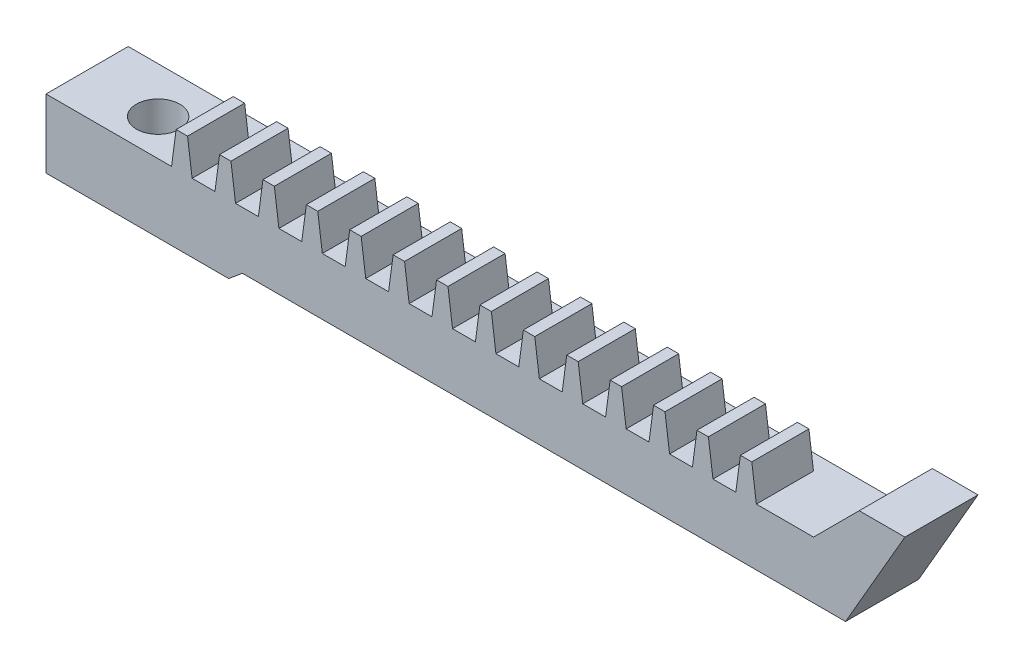
from build123d import *

# Parameters (mm, degrees)
P_IDAT_VYSUNUT_M1_DEPTH       = 3.6
ODEBRAT_VYSUNUT_M1_DEPTH      = 3
ODEBRAT_VYSUNUT_M1_DEPTH_BACK = 4
P_IDAT_VYSUNUT_M2_DEPTH       = 2.5
LINPOLE1_COUNT                = 12
LINPOLE1_PITCH                = 1.9
LINPOLE1_COL_COUNT            = 3
LINPOLE1_COL_PITCH            = 1.9
SKICA5_R                      = 0.95
ODEBRAT_VYSUNUT_M2_DEPTH      = 5


with BuildPart() as part:
    # Skica1 → Přidat vysunutím1 (new body)
    with BuildSketch(Plane.XY):
        Polygon((0, 0), (0, -3), (8, -3), (8.595876796, -2.5), (35, -2.5), (37.598076211, 2), (35.598076211, 2), (33.598076211, 0), align=None)
    extrude(amount=P_IDAT_VYSUNUT_M1_DEPTH)

    # Skica2 → Odebrat vysunutím1 (cut, two sides)
    with BuildSketch(Plane(origin=(0, 0, 0), x_dir=(1, 0, 0), z_dir=(0, 1, 0))) as odebrat_vysunut_m1_sk:
        Polygon((8, 0), (8.595876796, -0.4), (37.598076211, -0.4), (37.598076211, 0), align=None)
    extrude(amount=ODEBRAT_VYSUNUT_M1_DEPTH, mode=Mode.SUBTRACT)
    extrude(odebrat_vysunut_m1_sk.sketch, amount=-ODEBRAT_VYSUNUT_M1_DEPTH_BACK, mode=Mode.SUBTRACT)

    # Skica3 → Přidat vysunutím2 (add)
    with BuildSketch(Plane(origin=(0, -4.2, 3.6), x_dir=(1, 0, 0), z_dir=(0, 0, -1))):
        Polygon((9.295876796, -4.2), (10.195876796, -4.2), (9.995876796, -5.7), (9.495876796, -5.7), align=None)
    p_idat_vysunut_m2 = extrude(amount=P_IDAT_VYSUNUT_M2_DEPTH)

    # LinPole1: Přidat vysunutím2 ×12
    with Locations(*[(i * LINPOLE1_PITCH, 0, 0) for i in range(1, LINPOLE1_COUNT)]):
        add(p_idat_vysunut_m2)

    # LinPole1 col: Přidat vysunutím2 ×3
    with Locations(*[(-i * LINPOLE1_COL_PITCH, 0, 0) for i in range(1, LINPOLE1_COL_COUNT)]):
        add(p_idat_vysunut_m2)

    # Skica5 → Odebrat vysunutím2 (cut)
    with BuildSketch(Plane.XZ.offset(3)):
        with Locations((3.314552363, 2.006068977)):
            Circle(SKICA5_R)
    extrude(amount=-ODEBRAT_VYSUNUT_M2_DEPTH, mode=Mode.SUBTRACT)


solid = part.part
